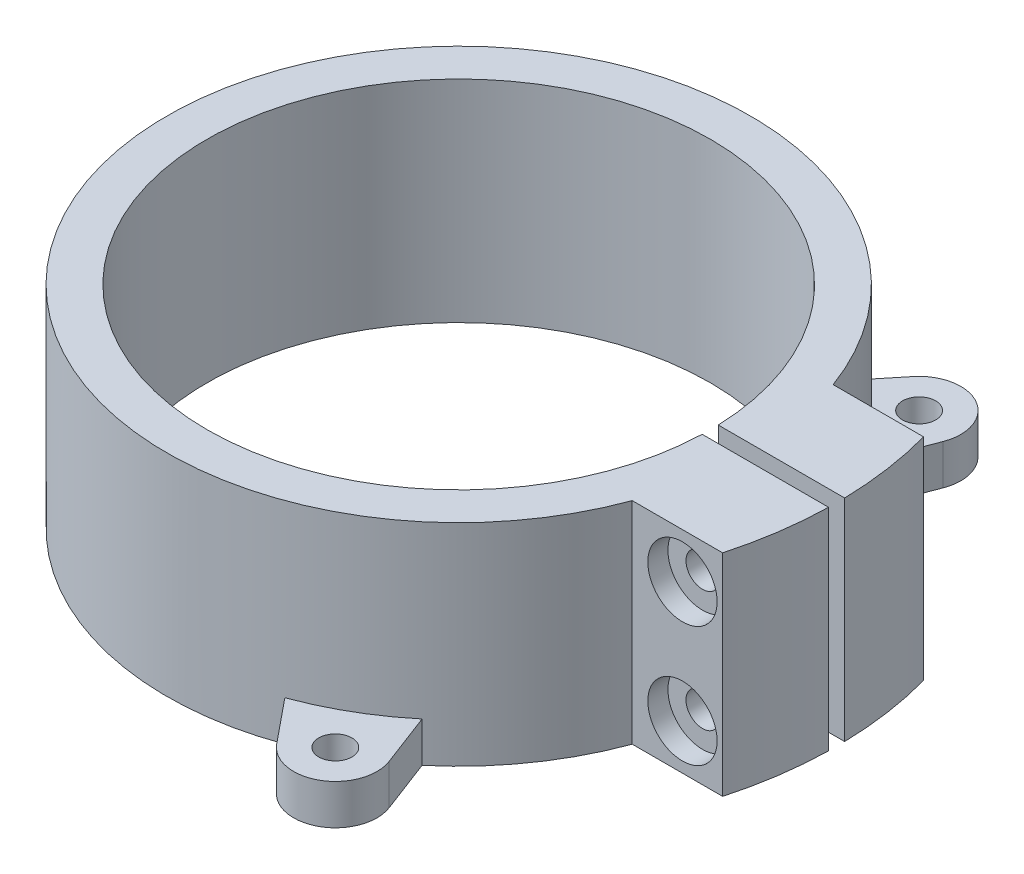
from build123d import *

# Parameters (mm, degrees)
SKETCH_1_W               = 4
SKETCH_1_H               = 21
EXTRUDE_2_DEPTH          = 21
SKETCH_2_W               = 12.68061601
SKETCH_2_H               = 1.6
CUT_EXTRUDE_1_DEPTH      = 1
CUT_EXTRUDE_1_DEPTH_BACK = 22
SKETCH_4_R               = 1.65
CUT_EXTRUDE_2_DEPTH      = 40.05
CUT_EXTRUDE_3_DEPTH      = 2
SKETCH_6_R               = 3.45
SKETCH_6_R_2             = 1.65
CUT_EXTRUDE_4_DEPTH      = 2
SKETCH_7_R               = 1.65
EXTRUDE_3_DEPTH          = 4


with BuildPart() as part:
    # 草图1 → 旋转1 (revolve)
    with BuildSketch(Plane.XY):
        with Locations((27.05, 0)):
            Rectangle(SKETCH_1_W, SKETCH_1_H)
    revolve(axis=Axis((0, 0, 0), (0, 1, 0)))

    # 草图3 → 凸台-拉伸2 (add, through all)
    with BuildSketch(Plane(origin=(0, 10.5, 0), x_dir=(1, 0, 0), z_dir=(0, 1, 0))):
        with BuildLine():
            Line((27.274576074, 10), (36.274576074, 10))
            ThreePointArc((36.274576074, 10), (37.627714112, 0), (36.274576074, -10))
            Line((36.274576074, -10), (27.274576074, -10))
            Line((27.274576074, -10), (27.274576074, 10))
        make_face()
    extrude(amount=-EXTRUDE_2_DEPTH)

    # 草图2 → 切除-拉伸1 (cut, two sides)
    with BuildSketch(Plane(origin=(0, 10.5, 0), x_dir=(1, 0, 0), z_dir=(0, 1, 0))) as cut_extrude_1_sk:
        with Locations((31.287406107, 0)):
            Rectangle(SKETCH_2_W, SKETCH_2_H)
    extrude(amount=CUT_EXTRUDE_1_DEPTH, mode=Mode.SUBTRACT)
    extrude(cut_extrude_1_sk.sketch, amount=-CUT_EXTRUDE_1_DEPTH_BACK, mode=Mode.SUBTRACT)

    # 草图4 → 切除-拉伸2 (cut, through all)
    with BuildSketch(Plane.XY.offset(10)):
        with Locations((32.274576074, 6)):
            Circle(SKETCH_4_R)
        with Locations((32.274576074, -6)):
            Circle(SKETCH_4_R)
    extrude(amount=-CUT_EXTRUDE_2_DEPTH, mode=Mode.SUBTRACT)

    # 草图5 → 切除-拉伸3 (cut)
    with BuildSketch(Plane(origin=(0, 0, -10), x_dir=(-1, 0, 0), z_dir=(0, 0, -1))):
        Polygon((-30.65799532, 8.8), (-33.891156827, 8.8), (-35.507737581, 6), (-33.891156827, 3.2), (-30.65799532, 3.2), (-29.041414566, 6), align=None)
        Polygon((-30.65799532, -3.2), (-33.891156827, -3.2), (-35.507737581, -6), (-33.891156827, -8.8), (-30.65799532, -8.8), (-29.041414566, -6), align=None)
    extrude(amount=-CUT_EXTRUDE_3_DEPTH, mode=Mode.SUBTRACT)

    # 草图6 → 切除-拉伸4 (cut)
    with BuildSketch(Plane.XY.offset(10)):
        with Locations((32.274576074, -6)):
            Circle(SKETCH_6_R)
        with Locations((32.274576074, -6)):
            Circle(SKETCH_6_R_2, mode=Mode.SUBTRACT)
        with Locations((32.274576074, 6)):
            Circle(SKETCH_6_R)
        with Locations((32.274576074, 6)):
            Circle(SKETCH_6_R_2, mode=Mode.SUBTRACT)
    extrude(amount=-CUT_EXTRUDE_4_DEPTH, mode=Mode.SUBTRACT)

    # 草图7 → 凸台-拉伸3 (add)
    with BuildSketch(Plane.XZ.offset(10.5)):
        with BuildLine():
            Line((-34.211268637, 4.096977397), (-28.616472529, 5))
            ThreePointArc((-28.616472529, 5), (-29.05, 0), (-28.616472529, -5))
            Line((-28.616472529, -5), (-34.211268637, -4.096977397))
            ThreePointArc((-34.211268637, -4.096977397), (-37.7, 0), (-34.211268637, 4.096977397))
        make_face()
        with Locations((-33.55, 0)):
            Circle(SKETCH_7_R, mode=Mode.SUBTRACT)
        with BuildLine():
            Line((20.653720823, 27.579339037), (18.638363283, 22.282592177))
            ThreePointArc((18.638363283, 22.282592177), (14.525, 25.15803798), (9.978109246, 27.282592177))
            Line((9.978109246, 27.282592177), (13.557547814, 31.676316433))
            ThreePointArc((13.557547814, 31.676316433), (18.85, 32.649157723), (20.653720823, 27.579339037))
        make_face()
        with Locations((16.775, 29.055152297)):
            Circle(SKETCH_7_R, mode=Mode.SUBTRACT)
        with BuildLine():
            Line((13.557547814, -31.676316433), (9.978109246, -27.282592177))
            ThreePointArc((9.978109246, -27.282592177), (14.525, -25.15803798), (18.638363283, -22.282592177))
            Line((18.638363283, -22.282592177), (20.653720823, -27.579339037))
            ThreePointArc((20.653720823, -27.579339037), (18.85, -32.649157723), (13.557547814, -31.676316433))
        make_face()
        with Locations((16.775, -29.055152297)):
            Circle(SKETCH_7_R, mode=Mode.SUBTRACT)
    extrude(amount=-EXTRUDE_3_DEPTH)


solid = part.part
